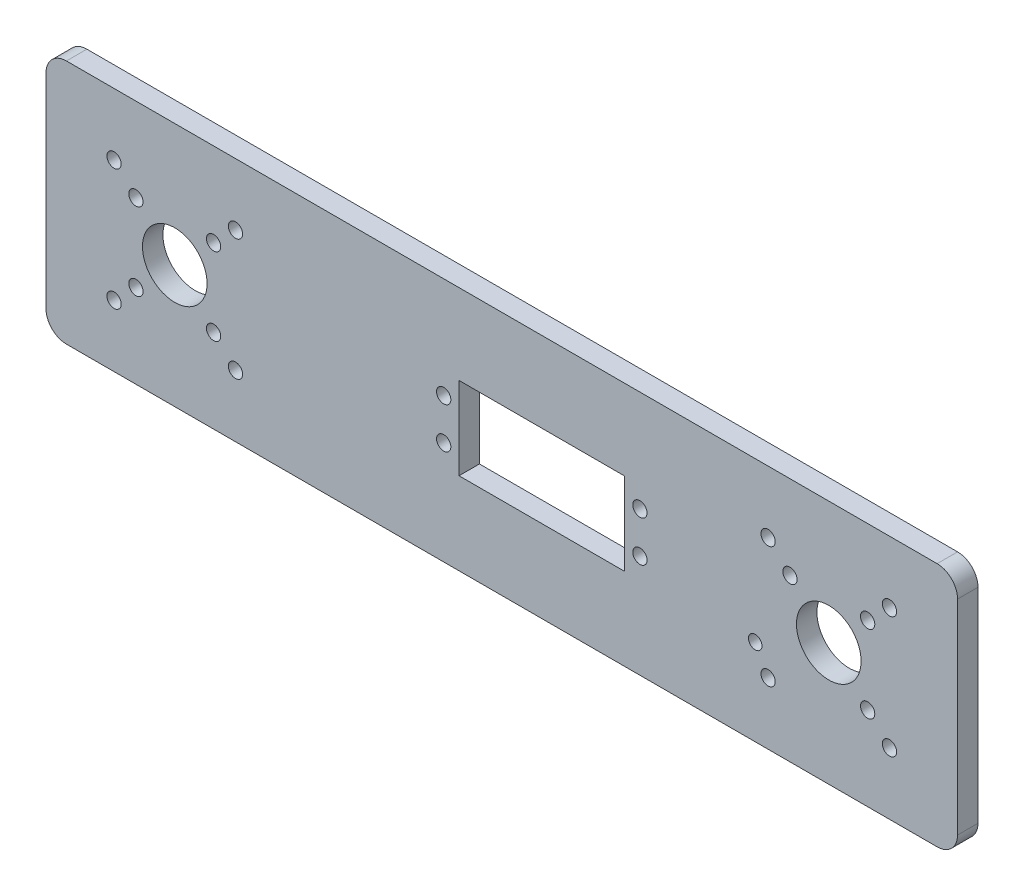
from build123d import *

# Parameters (mm, degrees)
SKETCH_1_R      = 7.905
SKETCH_1_R_2    = 1.75
SKETCH_1_R_3    = 1.65
SKETCH_1_W      = 40.5
SKETCH_1_H      = 20.2
EXTRUDE_1_DEPTH = 5


with BuildPart() as part:
    # 草图1 → 凸台-拉伸1 (new body)
    with BuildSketch(Plane.XY):
        with BuildLine():
            Line((106.5, -30), (-106.5, -30))
            ThreePointArc((-106.5, -30), (-110.035533906, -28.535533906), (-111.5, -25))
            Line((-111.5, -25), (-111.5, 25))
            ThreePointArc((-111.5, 25), (-110.035533906, 28.535533906), (-106.5, 30))
            Line((-106.5, 30), (106.5, 30))
            ThreePointArc((106.5, 30), (110.035533906, 28.535533906), (111.5, 25))
            Line((111.5, 25), (111.5, -25))
            ThreePointArc((111.5, -25), (110.035533906, -28.535533906), (106.5, -30))
        make_face()
        with Locations((-80, 0)):
            Circle(SKETCH_1_R, mode=Mode.SUBTRACT)
        with Locations((80, 0)):
            Circle(SKETCH_1_R, mode=Mode.SUBTRACT)
        with Locations((33.788860906, -4.762314657)):
            Circle(SKETCH_1_R_2, mode=Mode.SUBTRACT)
        with Locations((33.788860906, 5.237685343)):
            Circle(SKETCH_1_R_2, mode=Mode.SUBTRACT)
        with Locations((-14.211139094, -4.762314657)):
            Circle(SKETCH_1_R_2, mode=Mode.SUBTRACT)
        with Locations((-14.211139094, 5.237685343)):
            Circle(SKETCH_1_R_2, mode=Mode.SUBTRACT)
        with Locations((-94.849242405, 14.849242405)):
            Circle(SKETCH_1_R_2, mode=Mode.SUBTRACT)
        with Locations((-94.849242405, -14.849242405)):
            Circle(SKETCH_1_R_2, mode=Mode.SUBTRACT)
        with Locations((-65.150757595, 14.849242405)):
            Circle(SKETCH_1_R_2, mode=Mode.SUBTRACT)
        with Locations((-65.150757595, -14.849242405)):
            Circle(SKETCH_1_R_2, mode=Mode.SUBTRACT)
        with Locations((65.150757595, -14.849242405)):
            Circle(SKETCH_1_R_2, mode=Mode.SUBTRACT)
        with Locations((94.849242405, -14.849242405)):
            Circle(SKETCH_1_R_2, mode=Mode.SUBTRACT)
        with Locations((65.150757595, 14.849242405)):
            Circle(SKETCH_1_R_2, mode=Mode.SUBTRACT)
        with Locations((94.849242405, 14.849242405)):
            Circle(SKETCH_1_R_2, mode=Mode.SUBTRACT)
        with Locations((-89.5, 9.5)):
            Circle(SKETCH_1_R_2, mode=Mode.SUBTRACT)
        with Locations((-89.5, -9.5)):
            Circle(SKETCH_1_R_2, mode=Mode.SUBTRACT)
        with Locations((-70.5, 9.5)):
            Circle(SKETCH_1_R_2, mode=Mode.SUBTRACT)
        with Locations((-70.5, -9.5)):
            Circle(SKETCH_1_R_2, mode=Mode.SUBTRACT)
        with Locations((89.5, -9.5)):
            Circle(SKETCH_1_R_2, mode=Mode.SUBTRACT)
        with Locations((62, -8.868327509)):
            Circle(SKETCH_1_R_3, mode=Mode.SUBTRACT)
        with Locations((70.5, 9.5)):
            Circle(SKETCH_1_R_2, mode=Mode.SUBTRACT)
        with Locations((89.5, 9.5)):
            Circle(SKETCH_1_R_2, mode=Mode.SUBTRACT)
        with Locations((9.788860906, 0.237685343)):
            Rectangle(SKETCH_1_W, SKETCH_1_H, mode=Mode.SUBTRACT)
    extrude(amount=EXTRUDE_1_DEPTH)


solid = part.part
